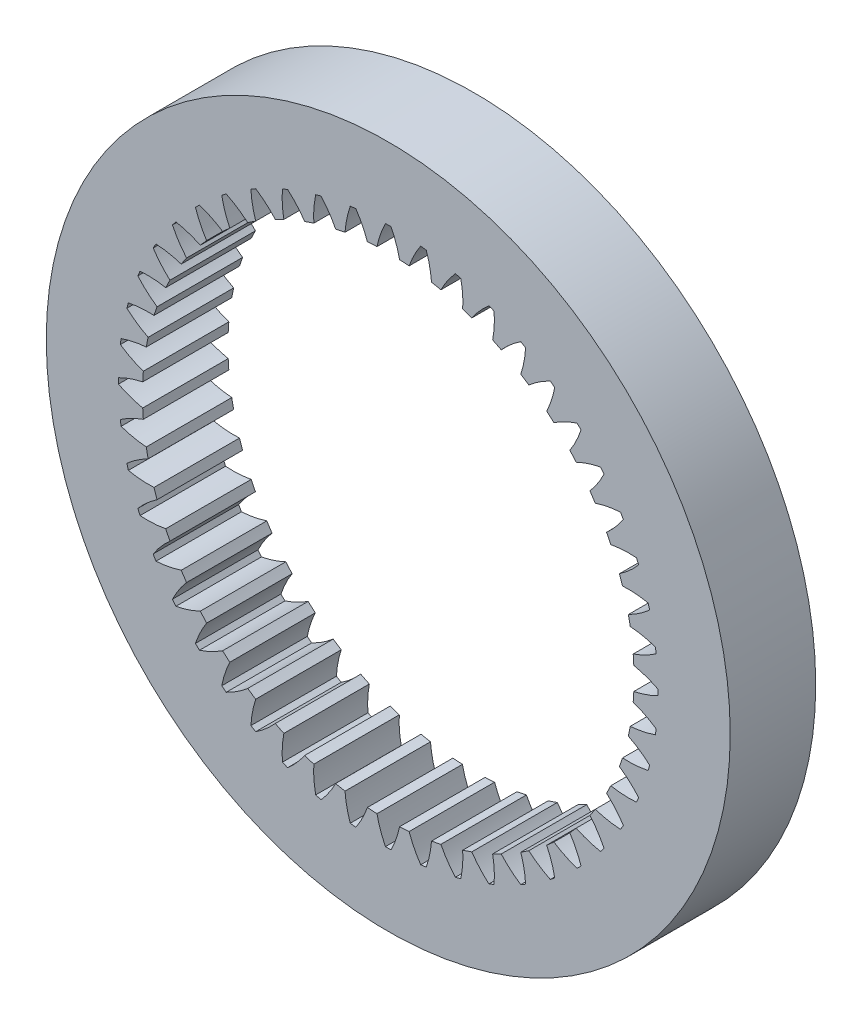
from build123d import *

# Parameters (mm, degrees)
GEARSKETCH_R       = 25.4
GEARBODY_DEPTH     = 6.35
BORESKETCH_R       = 18.25625
BODYBORE_DEPTH     = 7.35
CUT_EXTRUDE2_DEPTH = 7.35
CIRPATTERN1_COUNT  = 48
CIRPATTERN1_ANGLE  = 352.5


with BuildPart() as part:
    # gearSketch → gearBody (new body)
    with BuildSketch(Plane.XY):
        Circle(GEARSKETCH_R)
    extrude(amount=GEARBODY_DEPTH)

    # boreSketch → bodyBore (cut, through all)
    with BuildSketch(Plane(origin=(0, 0, 0), x_dir=(-1, 0, 0), z_dir=(0, 0, -1))):
        Circle(BORESKETCH_R)
    extrude(amount=-BODYBORE_DEPTH, mode=Mode.SUBTRACT)

    # toothCut1 → Cut-Extrude2 (cut, through all)
    with BuildSketch(Plane(origin=(-279.4, 0, 0), x_dir=(-1, 0, 0), z_dir=(0, 0, -1))):
        with BuildLine():
            Line((-279.4, 0), (-280.238786192, 18.23697074))
            ThreePointArc((-280.238786192, 18.23697074), (-279.98257607, 19.159651848), (-279.608375949, 20.041104242))
            ThreePointArc((-279.608375949, 20.041104242), (-279.4, 20.0421875), (-279.191624051, 20.041104242))
            ThreePointArc((-279.191624051, 20.041104242), (-278.81742393, 19.159651848), (-278.561213808, 18.23697074))
            Line((-278.561213808, 18.23697074), (-279.4, 0))
        make_face()
    cut_extrude2 = extrude(amount=-CUT_EXTRUDE2_DEPTH, mode=Mode.SUBTRACT)

    # CirPattern1: Cut-Extrude2 ×48 about axis
    cirpattern1_axis = Axis((0, 0, -80.9), (0, 0, 1))
    for i in range(1, CIRPATTERN1_COUNT):
        add(cut_extrude2.rotate(cirpattern1_axis, i * CIRPATTERN1_ANGLE / (CIRPATTERN1_COUNT - 1)), mode=Mode.SUBTRACT)


solid = part.part
